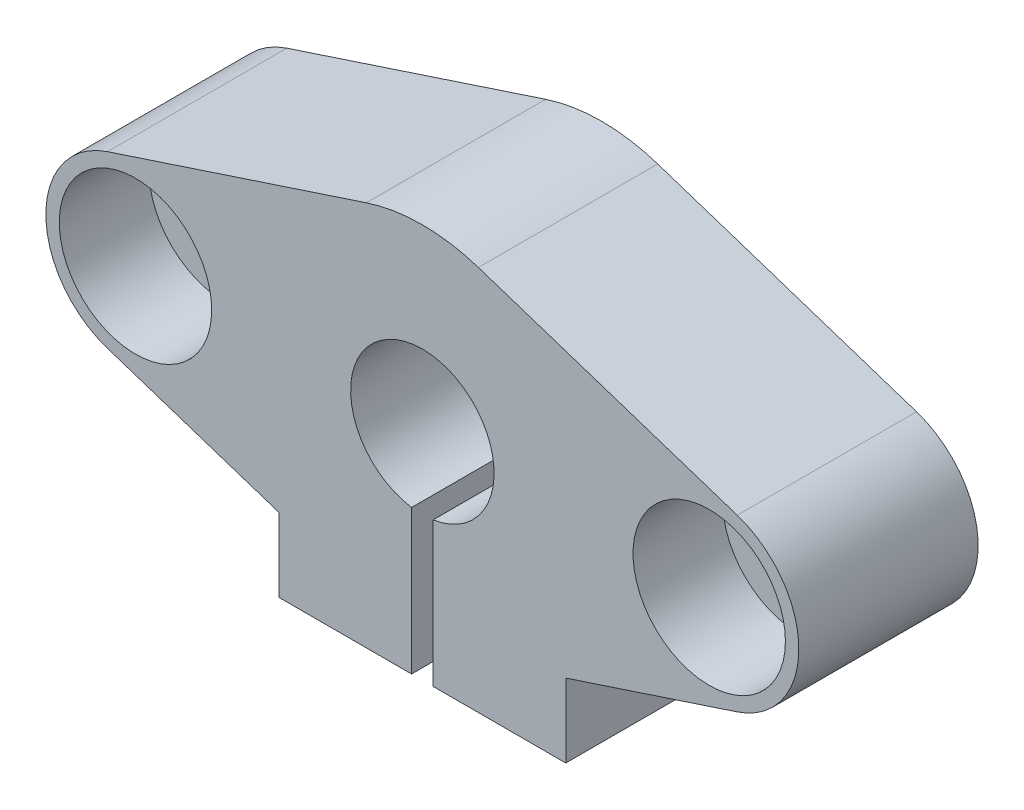
from build123d import *

# Parameters (mm, degrees)
SKETCH_1_R          = 10
SKETCH_1_R_2        = 4
EXTRUDE_1_DEPTH     = 10
EXTRUDE_2_DEPTH     = 5
SKETCH_4_R          = 2.75
CUT_EXTRUDE_6_DEPTH = 5
CUT_EXTRUDE_5_DEPTH = 5
EXTRUDE_3_DEPTH     = 10
CUT_EXTRUDE_8_DEPTH = 11
SKETCH_7_R          = 4.25
EXTRUDE_4_DEPTH     = 5


with BuildPart() as part:
    # 草图1 → 凸台-拉伸1 (new body)
    with BuildSketch(Plane.XY):
        Circle(SKETCH_1_R)
        Circle(SKETCH_1_R_2, mode=Mode.SUBTRACT)
    extrude(amount=EXTRUDE_1_DEPTH)

    # 草图2 → 凸台-拉伸2 (add)
    with BuildSketch(Plane.XY):
        with BuildLine():
            Line((2.8e-08, 10), (-21.5, 10))
            Line((-21.5, 10), (-21.5, -10))
            Line((-21.5, -10), (-1.9e-08, -10))
            ThreePointArc((-1.9e-08, -10), (-10, 2.4e-08), (2.8e-08, 10))
        make_face()
        with BuildLine():
            Line((21.5, 10), (2.8e-08, 10))
            ThreePointArc((2.8e-08, 10), (7.071067822, 7.071067802), (10, 0))
            ThreePointArc((10, 0), (7.071067805, -7.071067819), (-1.9e-08, -10))
            Line((-1.9e-08, -10), (21.5, -10))
            Line((21.5, -10), (21.5, 10))
        make_face()
    extrude(amount=EXTRUDE_2_DEPTH)

    # 草图4 → 切除-拉伸6 (cut)
    with BuildSketch(Plane.XY):
        with Locations((-16, 0)):
            Circle(SKETCH_4_R)
        with Locations((16, 0)):
            Circle(SKETCH_4_R)
    extrude(amount=CUT_EXTRUDE_6_DEPTH, mode=Mode.SUBTRACT)

    # 草图3 → 切除-拉伸5 (cut)
    with BuildSketch(Plane.XY):
        with BuildLine():
            ThreePointArc((-17.5625, -4.749588798), (-21, 0), (-17.5625, 4.749588798))
            Line((-17.5625, 4.749588798), (-3.125, 9.499177596))
            ThreePointArc((-3.125, 9.499177596), (-1.582438631, 9.874000607), (0, 10))
            Line((0, 10), (-21.5, 10))
            Line((-21.5, 10), (-21.5, -10))
            Line((-21.5, -10), (0, -10))
            ThreePointArc((0, -10), (-1.582438631, -9.874000607), (-3.125, -9.499177596))
            Line((-3.125, -9.499177596), (-17.5625, -4.749588798))
        make_face()
        with BuildLine():
            Line((21.5, 10), (0, 10))
            ThreePointArc((0, 10), (1.582438631, 9.874000607), (3.125, 9.499177596))
            Line((3.125, 9.499177596), (17.5625, 4.749588798))
            ThreePointArc((17.5625, 4.749588798), (20.050462937, 2.93150985), (21, 0))
            ThreePointArc((21, 0), (20.050462937, -2.93150985), (17.5625, -4.749588798))
            Line((17.5625, -4.749588798), (3.125, -9.499177596))
            ThreePointArc((3.125, -9.499177596), (1.582438631, -9.874000607), (0, -10))
            Line((0, -10), (21.5, -10))
            Line((21.5, -10), (21.5, 10))
        make_face()
        with BuildLine():
            Line((21.5, 10), (0, 10))
            ThreePointArc((0, 10), (1.582438631, 9.874000607), (3.125, 9.499177596))
            Line((3.125, 9.499177596), (17.5625, 4.749588798))
            ThreePointArc((17.5625, 4.749588798), (20.050462937, 2.93150985), (21, 0))
            ThreePointArc((21, 0), (20.050462937, -2.93150985), (17.5625, -4.749588798))
            Line((17.5625, -4.749588798), (3.125, -9.499177596))
            ThreePointArc((3.125, -9.499177596), (1.582438631, -9.874000607), (0, -10))
            Line((0, -10), (21.5, -10))
            Line((21.5, -10), (21.5, 10))
        make_face()
        with BuildLine():
            ThreePointArc((-17.5625, -4.749588798), (-21, 0), (-17.5625, 4.749588798))
            Line((-17.5625, 4.749588798), (-3.125, 9.499177596))
            ThreePointArc((-3.125, 9.499177596), (-1.582438631, 9.874000607), (0, 10))
            Line((0, 10), (-21.5, 10))
            Line((-21.5, 10), (-21.5, -10))
            Line((-21.5, -10), (0, -10))
            ThreePointArc((0, -10), (-1.582438631, -9.874000607), (-3.125, -9.499177596))
            Line((-3.125, -9.499177596), (-17.5625, -4.749588798))
        make_face()
    extrude(amount=CUT_EXTRUDE_5_DEPTH, mode=Mode.SUBTRACT)

    # 草图5 → 凸台-拉伸3 (add)
    with BuildSketch(Plane.XY):
        with BuildLine():
            Line((-8, -6), (-8, -12))
            Line((-8, -12), (8, -12))
            Line((8, -12), (8, -6))
            ThreePointArc((8, -6), (0, -10), (-8, -6))
        make_face()
    extrude(amount=EXTRUDE_3_DEPTH)

    # 草图6 → 切除-拉伸8 (cut, through all)
    with BuildSketch(Plane.XY):
        with BuildLine():
            Line((-0.6, -12), (0.6, -12))
            Line((0.6, -12), (0.6, -3.954743987))
            ThreePointArc((0.6, -3.954743987), (0, -4), (-0.6, -3.954743987))
            Line((-0.6, -3.954743987), (-0.6, -12))
        make_face()
    extrude(amount=CUT_EXTRUDE_8_DEPTH, mode=Mode.SUBTRACT)

    # 草图7 → 凸台-拉伸4 (add)
    with BuildSketch(Plane.XY.offset(5)):
        with BuildLine():
            Line((-17.5625, -4.749588798), (-8, -7.89542034))
            Line((-8, -7.89542034), (-8, -6))
            ThreePointArc((-8, -6), (-9.539262696, 3.000411174), (-3.125, 9.499177596))
            Line((-3.125, 9.499177596), (-17.5625, 4.749588798))
            ThreePointArc((-17.5625, 4.749588798), (-21, 0), (-17.5625, -4.749588798))
        make_face()
        with Locations((-16, 0)):
            Circle(SKETCH_7_R, mode=Mode.SUBTRACT)
        with BuildLine():
            Line((8, -6), (8, -7.89542034))
            Line((8, -7.89542034), (17.5625, -4.749588798))
            ThreePointArc((17.5625, -4.749588798), (21, 0), (17.5625, 4.749588798))
            Line((17.5625, 4.749588798), (3.125, 9.499177596))
            ThreePointArc((3.125, 9.499177596), (9.539262696, 3.000411174), (8, -6))
        make_face()
        with Locations((16, 0)):
            Circle(SKETCH_7_R, mode=Mode.SUBTRACT)
    extrude(amount=EXTRUDE_4_DEPTH)


solid = part.part
